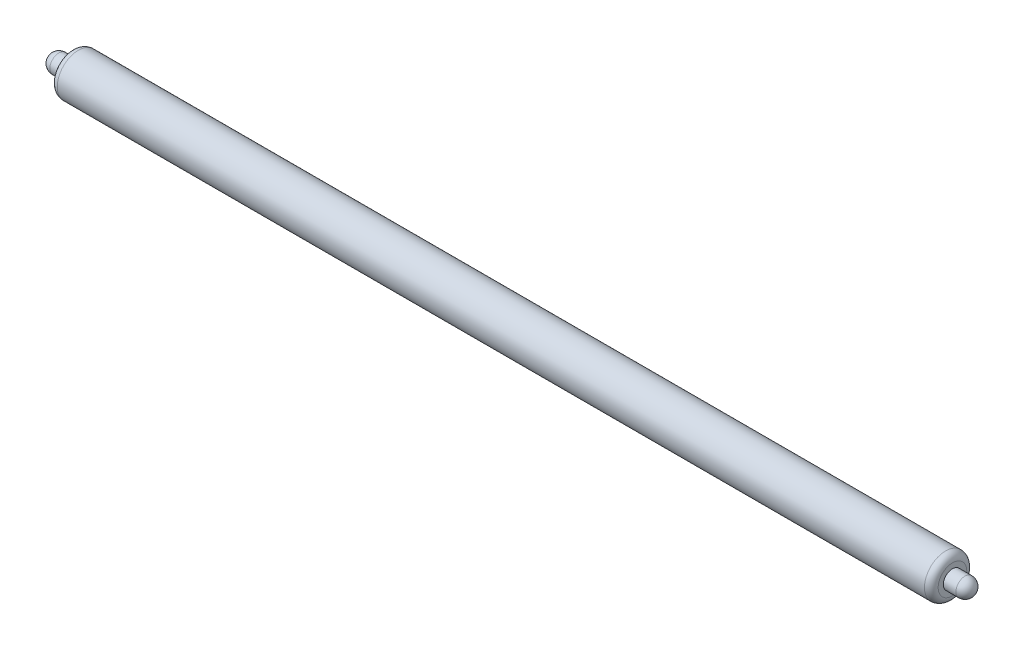
from build123d import *

# Parameters (mm, degrees)
ESBO_O1_R                = 9.25
RESSALTO_EXTRUS_O1_DEPTH = 385
ESBO_O2_R                = 4
RESSALTO_EXTRUS_O2_DEPTH = 9.5
FILETE1_R                = 3
ESBO_O3_R                = 4
RESSALTO_EXTRUS_O3_DEPTH = 9.5
FILETE2_R                = 4


with BuildPart() as part:
    # Esboço1 → Ressalto-extrusão1 (new body)
    with BuildSketch(Plane(origin=(0, 0, 0), x_dir=(0, 0, -1), z_dir=(1, 0, 0))):
        Circle(ESBO_O1_R)
    extrude(amount=RESSALTO_EXTRUS_O1_DEPTH)

    # Esboço2 → Ressalto-extrusão2 (add)
    with BuildSketch(Plane.ZY):
        Circle(ESBO_O2_R)
    extrude(amount=RESSALTO_EXTRUS_O2_DEPTH)

    # Filete1
    filete1_edges = [part.edges().sort_by_distance(p)[0] for p in [
        (0, 0, 9.25),
        (385, 0, 9.25),
    ]]
    fillet(filete1_edges, radius=FILETE1_R)

    # Esboço3 → Ressalto-extrusão3 (add)
    with BuildSketch(Plane(origin=(385, 0, 0), x_dir=(0, 0, -1), z_dir=(1, 0, 0))):
        Circle(ESBO_O3_R)
    extrude(amount=RESSALTO_EXTRUS_O3_DEPTH)

    # Filete2
    filete2_edges = [part.edges().sort_by_distance(p)[0] for p in [
        (394.5, 0, 4),
        (-9.5, 0, -4),
    ]]
    fillet(filete2_edges, radius=FILETE2_R)


solid = part.part
